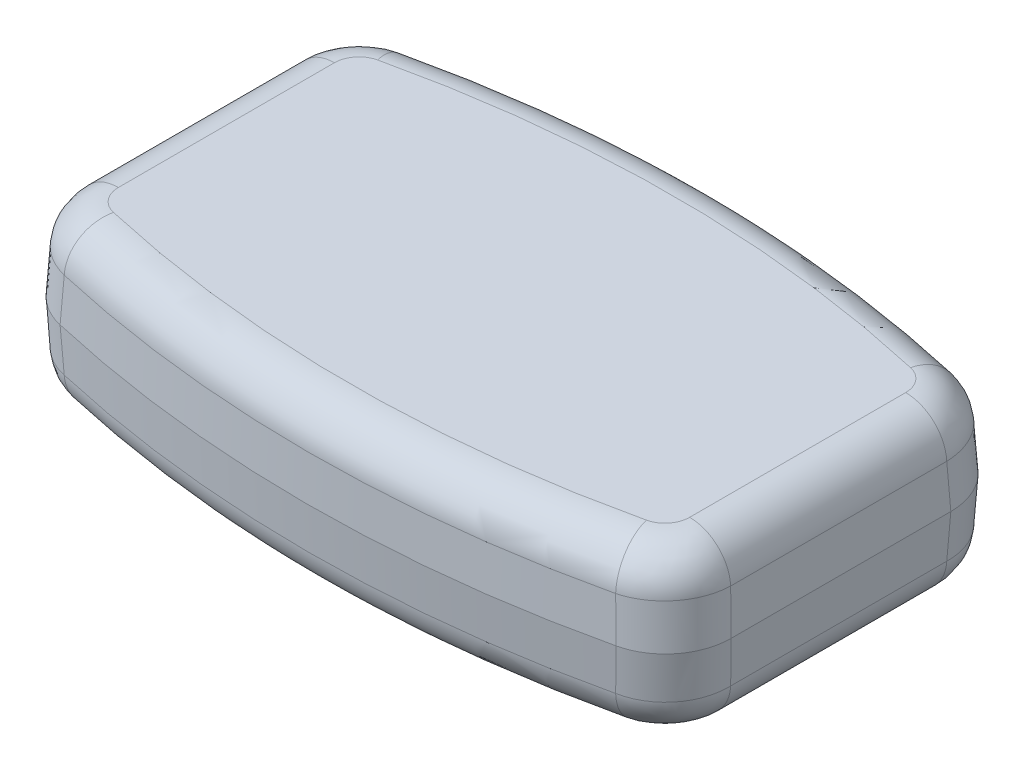
from build123d import *

# Parameters (mm, degrees)
BOSS_EXTRUDE1_DEPTH           = 10
BOSS_EXTRUDE1_TAPER           = 3
BOSS_EXTRUDE1_OTHER_WAY_DEPTH = 10
BOSS_EXTRUDE1_OTHER_WAY_TAPER = 3
FILLET1_R                     = 8
FILLET2_R                     = 5


with BuildPart() as part:
    # Sketch2 → Boss-Extrude1 (new body)
    with BuildSketch(Plane(origin=(0, 0, 0), x_dir=(1, 0, 0), z_dir=(0, 1, 0))):
        with BuildLine():
            ThreePointArc((40, 19.568322948), (20.183552336, 23.635877954), (2.99e-07, 25))
            ThreePointArc((2.99e-07, 25), (-20.183552039, 23.635877994), (-40, 19.568322948))
            Line((-40, 19.568322948), (-40, -19.568322948))
            ThreePointArc((-40, -19.568322948), (-20.183552538, -23.635877926), (-7.08e-07, -25))
            ThreePointArc((-7.08e-07, -25), (20.183551836, -23.635878022), (40, -19.568322948))
            Line((40, -19.568322948), (40, 19.568322948))
        make_face()
    extrude(amount=BOSS_EXTRUDE1_DEPTH, taper=BOSS_EXTRUDE1_TAPER)

    # Sketch2 → Boss-Extrude1 other way (add)
    with BuildSketch(Plane(origin=(0, 0, 0), x_dir=(1, 0, 0), z_dir=(0, 1, 0))):
        with BuildLine():
            ThreePointArc((40, 19.568322948), (20.183552336, 23.635877954), (2.99e-07, 25))
            ThreePointArc((2.99e-07, 25), (-20.183552039, 23.635877994), (-40, 19.568322948))
            Line((-40, 19.568322948), (-40, -19.568322948))
            ThreePointArc((-40, -19.568322948), (-20.183552538, -23.635877926), (-7.08e-07, -25))
            ThreePointArc((-7.08e-07, -25), (20.183551836, -23.635878022), (40, -19.568322948))
            Line((40, -19.568322948), (40, 19.568322948))
        make_face()
    extrude(amount=-BOSS_EXTRUDE1_OTHER_WAY_DEPTH, taper=BOSS_EXTRUDE1_OTHER_WAY_TAPER)

    # Fillet1
    fillet1_edges = [part.edges().sort_by_distance(p)[0] for p in [
        (-39.737961104, 5, 19.368665505),
        (39.737961104, 5, 19.368665505),
        (39.737961104, 5, -19.368665505),
        (-39.737961104, 5, -19.368665505),
        (-39.737961104, -5, 19.368665505),
        (-39.737961104, -5, -19.368665505),
        (39.737961104, -5, -19.368665505),
        (39.737961104, -5, 19.368665505),
    ]]
    fillet(fillet1_edges, radius=FILLET1_R)

    # Fillet2
    fillet2_edges = [part.edges().sort_by_distance(p)[0] for p in [
        (-37.733680638, -10, -17.92036042),
        (-39.475922207, -10, 0),
        (-37.733680638, -10, 17.92036042),
        (16.737652644, -10, 23.535862012),
        (37.733680638, -10, 17.92036042),
        (39.475922207, -10, 0),
        (37.733680638, -10, -17.92036042),
        (-37.733680638, 10, 17.92036042),
        (-39.475922207, 10, 0),
        (-37.733680638, 10, -17.92036042),
        (-16.737652847, 10, -23.535861989),
        (37.733680638, 10, -17.92036042),
        (39.475922207, 10, 0),
        (37.733680638, 10, 17.92036042),
        (-16.737652847, -10, -23.535861989),
        (16.737652644, 10, 23.535862012),
    ]]
    fillet(fillet2_edges, radius=FILLET2_R)


solid = part.part
